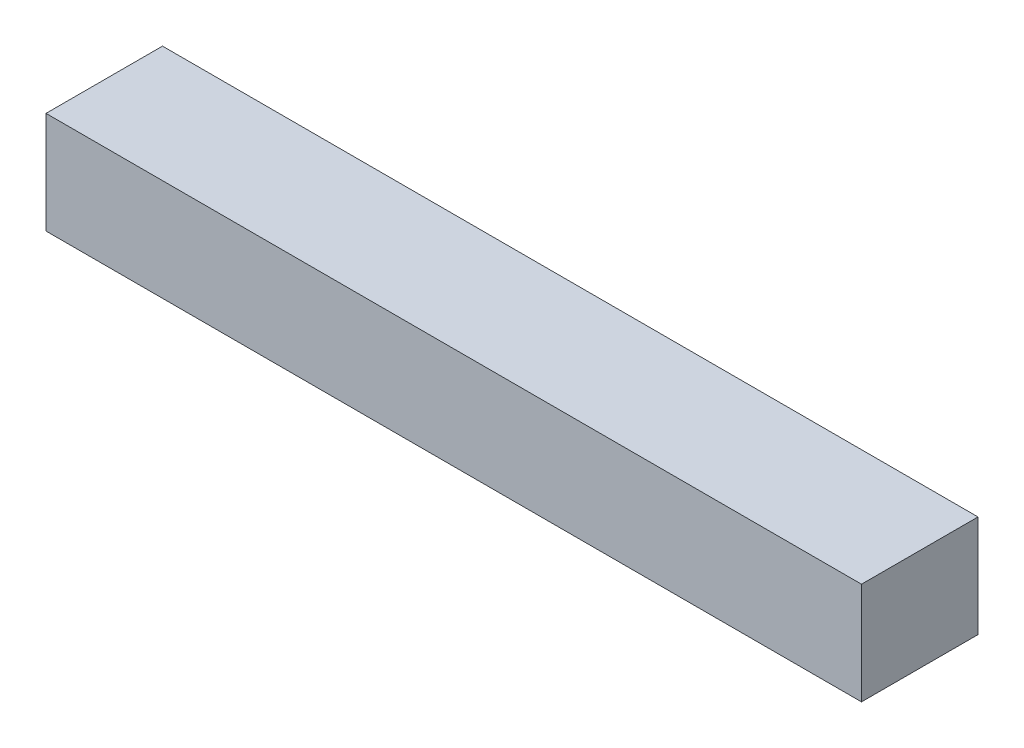
from build123d import *

# Parameters (mm, degrees)
SKETCH1_W           = 56
SKETCH1_H           = 7
BOSS_EXTRUDE1_DEPTH = 8
SCALE1_SCALE        = 2


with BuildPart() as part:
    # Sketch1 → Boss-Extrude1 (new body)
    with BuildSketch(Plane.XY):
        Rectangle(SKETCH1_W, SKETCH1_H)
    extrude(amount=BOSS_EXTRUDE1_DEPTH)


with BuildPart() as part_1:
    # Scale1: scaled about (0, 0, 4)
    add(part.part.scale(SCALE1_SCALE).moved(Location((0, 0, -4))))


solid = part_1.part
